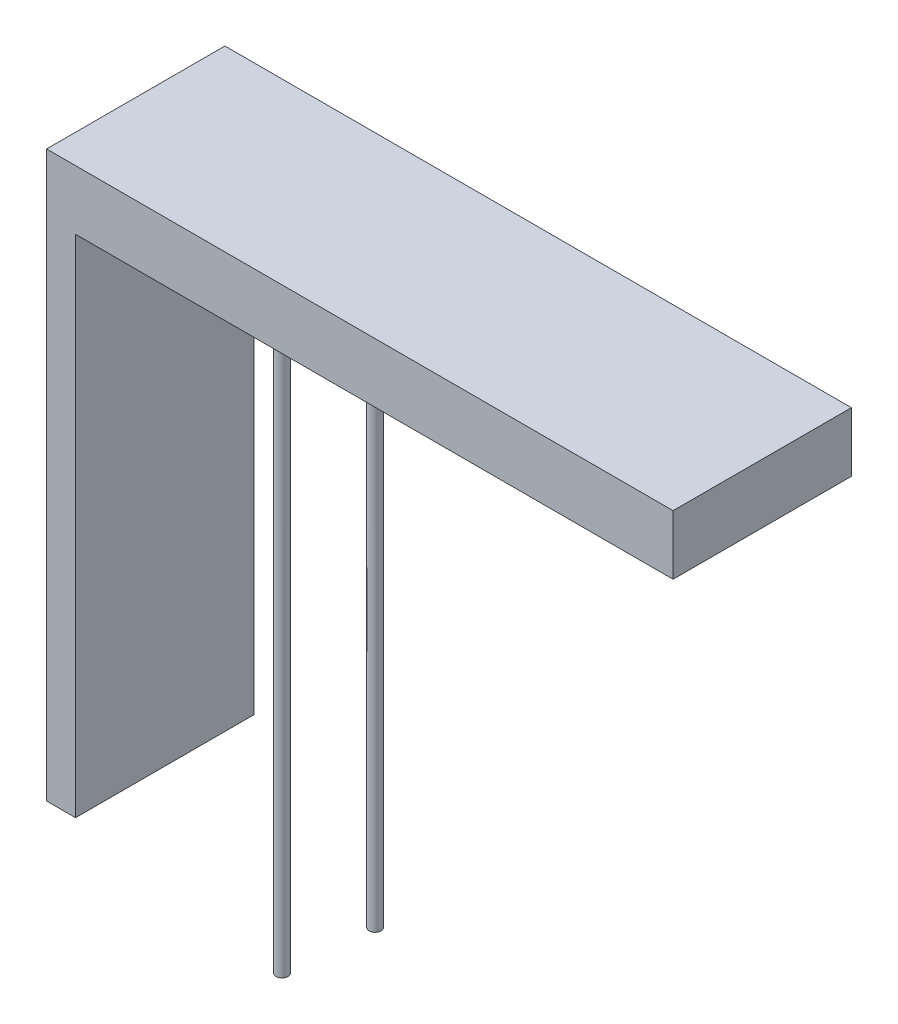
from build123d import *

# Parameters (mm, degrees)
EXTRUSION1_DEPTH = 6
ESQUISSE2_R      = 0.2
EXTRUSION2_DEPTH = 20


with BuildPart() as part:
    # Esquisse1 → Extrusion1 (new body)
    with BuildSketch(Plane.XY):
        Polygon((123.733692342, 14.5), (123.733692342, 31.5), (143.838461576, 31.5), (143.838461576, 33.5), (122.759551823, 33.5), (122.759551823, 14.5), align=None)
    extrude(amount=EXTRUSION1_DEPTH)

    # Esquisse2 → Extrusion2 (add)
    with BuildSketch(Plane.XZ.offset(-31.5)):
        with Locations((128.735391716, 4.056660757)):
            Circle(ESQUISSE2_R)
        with Locations((128.971557812, 1.159084415)):
            Circle(ESQUISSE2_R)
    extrude(amount=EXTRUSION2_DEPTH)


solid = part.part
